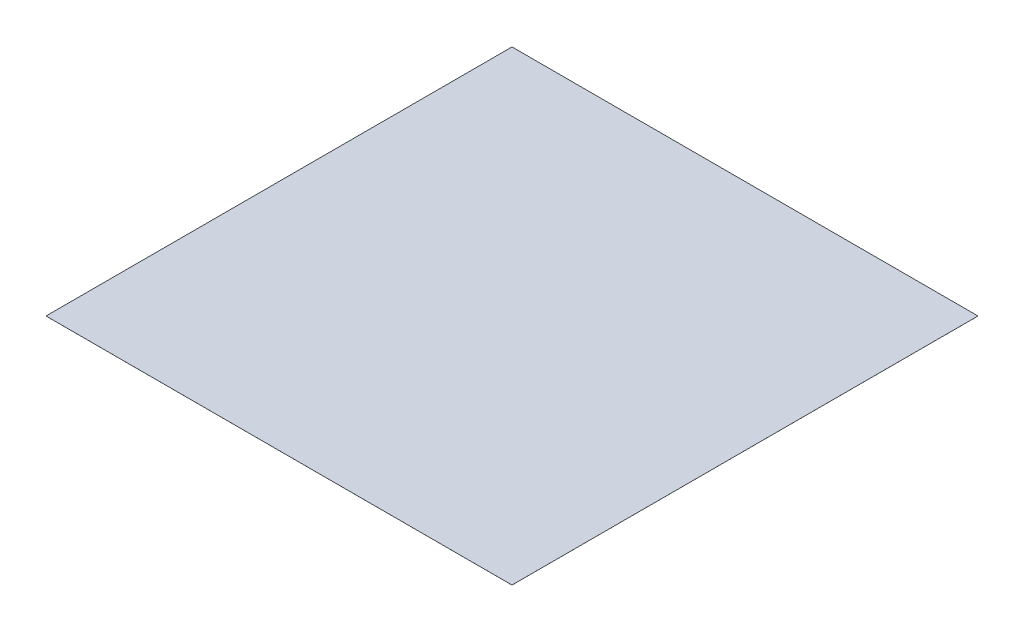
from build123d import *

# Parameters (mm, degrees)
SKETCH2_W           = 250000
SKETCH2_H           = 250000
BOSS_EXTRUDE1_DEPTH = 10


with BuildPart() as part:
    # Sketch2 → Boss-Extrude1 (new body)
    with BuildSketch(Plane(origin=(0, 0, 0), x_dir=(1, 0, 0), z_dir=(0, 1, 0))):
        Rectangle(SKETCH2_W, SKETCH2_H)
    extrude(amount=BOSS_EXTRUDE1_DEPTH)


solid = part.part
